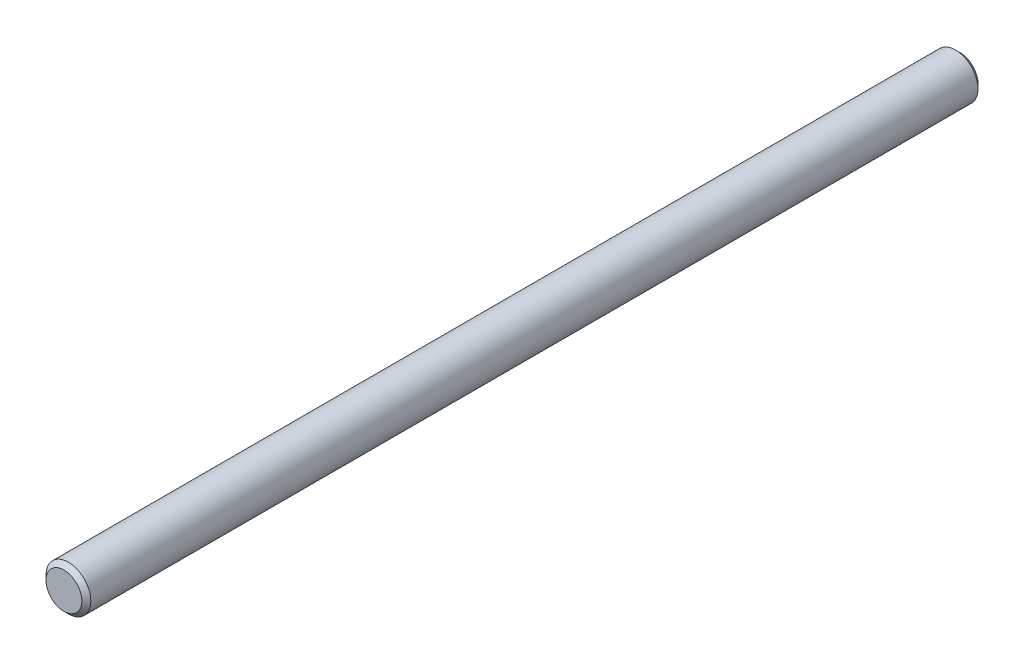
from build123d import *

# Parameters (mm, degrees)
SKIZZE1_R                       = 2.5
AUFSATZ_LINEAR_AUSTRAGEN1_DEPTH = 100
FASE1_SIZE                      = 0.5


with BuildPart() as part:
    # Skizze1 → Aufsatz-Linear austragen1 (new body)
    with BuildSketch(Plane.XY):
        Circle(SKIZZE1_R)
    extrude(amount=AUFSATZ_LINEAR_AUSTRAGEN1_DEPTH)

    # Fase1
    fase1_edges = [part.edges().sort_by_distance(p)[0] for p in [
        (-2.5, 0, 0),
        (-2.5, 0, 100),
    ]]
    chamfer(fase1_edges, length=FASE1_SIZE)


solid = part.part
